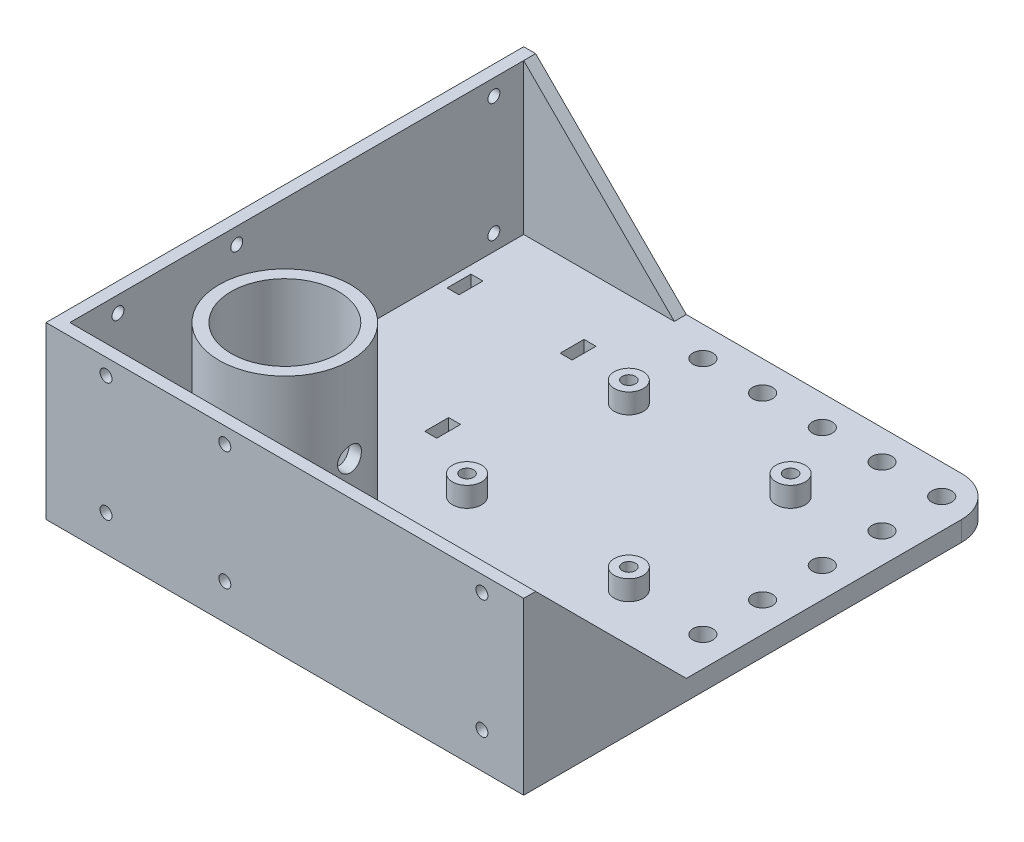
from build123d import *

# Parameters (mm, degrees)
SKETCH1_W           = 120
SKETCH1_H           = 120
BOSS_EXTRUDE1_DEPTH = 5
BOSS_EXTRUDE2_START = -5
BOSS_EXTRUDE2_DEPTH = 42.84
SKETCH6_R           = 1.5
CUT_EXTRUDE1_DEPTH  = 121
BOSS_EXTRUDE3_DEPTH = 3
SKETCH7_R           = 13.5
CUT_EXTRUDE2_DEPTH  = 6
SKETCH8_R           = 16.5
SKETCH8_R_2         = 13.5
BOSS_EXTRUDE5_DEPTH = 37.84
SKETCH9_R           = 3
CUT_EXTRUDE3_DEPTH  = 91
SKETCH10_R          = 2.5
SKETCH10_W          = 6
SKETCH10_H          = 3
CUT_EXTRUDE4_DEPTH  = 6.0000001
FILLET1_R           = 10
SKETCH11_R          = 1.65
CUT_EXTRUDE5_DEPTH  = 6.0000001
SKETCH12_R          = 3.65
SKETCH12_R_2        = 1.65
BOSS_EXTRUDE6_DEPTH = 5
CHAMFER1_SIZE       = 2.5


with BuildPart() as part:
    # Sketch1 → Boss-Extrude1 (new body)
    with BuildSketch(Plane(origin=(0, 0, 0), x_dir=(1, 0, 0), z_dir=(0, 1, 0))):
        with Locations((30, 30)):
            Rectangle(SKETCH1_W, SKETCH1_H)
    extrude(amount=-BOSS_EXTRUDE1_DEPTH)

    # Sketch2 → Boss-Extrude2 (add)
    with BuildSketch(Plane(origin=(0, 0, 0), x_dir=(1, 0, 0), z_dir=(0, 1, 0)).offset(BOSS_EXTRUDE2_START)):
        Polygon((-30, 90), (-27, 90), (-27, -27), (90, -27), (90, -30), (-30, -30), align=None)
    extrude(amount=BOSS_EXTRUDE2_DEPTH)

    # Sketch6 → Cut-Extrude1 (cut, through all)
    with BuildSketch(Plane.XY.offset(30)):
        with Locations((-14.919953083, 33.839953083)):
            Circle(SKETCH6_R)
        with Locations((14.919953083, 33.839953083)):
            Circle(SKETCH6_R)
        with Locations((14.919953083, 4.000046917)):
            Circle(SKETCH6_R)
        with Locations((-14.919953083, 4.000046917)):
            Circle(SKETCH6_R)
        with Locations((79.499953083, 33.839953083)):
            Circle(SKETCH6_R)
        with Locations((79.499953083, 4.000046917)):
            Circle(SKETCH6_R)
    cut_extrude1 = extrude(amount=-CUT_EXTRUDE1_DEPTH, mode=Mode.SUBTRACT)

    # Mirror1: Cut-Extrude1 across plane
    add(cut_extrude1.mirror(Plane(origin=(0, 0, 0), x_dir=(-0.707106781, 0, 0.707106781), z_dir=(-0.707106781, 0, -0.707106781))), mode=Mode.SUBTRACT)

    # Sketch3 → Boss-Extrude3 (add)
    with BuildSketch(Plane(origin=(90, 0, 0), x_dir=(0, 0, -1), z_dir=(1, 0, 0))):
        Polygon((-27, 37.84), (-27, 0), (10.84, 0), align=None)
    boss_extrude3 = extrude(amount=-BOSS_EXTRUDE3_DEPTH)

    # Sketch7 → Cut-Extrude2 (cut, through all)
    with BuildSketch(Plane(origin=(0, 0, 0), x_dir=(1, 0, 0), z_dir=(0, 1, 0))):
        Circle(SKETCH7_R)
    extrude(amount=-CUT_EXTRUDE2_DEPTH, mode=Mode.SUBTRACT)

    # Sketch8 → Boss-Extrude5 (add, through all)
    with BuildSketch(Plane(origin=(0, 0, 0), x_dir=(1, 0, 0), z_dir=(0, 1, 0))):
        Circle(SKETCH8_R)
        Circle(SKETCH8_R_2, mode=Mode.SUBTRACT)
    extrude(amount=BOSS_EXTRUDE5_DEPTH)

    # Sketch9 → Cut-Extrude3 (cut, through all)
    with BuildSketch(Plane(origin=(0, 0, 0), x_dir=(0, 0, -1), z_dir=(1, 0, 0))):
        with Locations((0, 16.42)):
            Circle(SKETCH9_R)
    cut_extrude3 = extrude(amount=CUT_EXTRUDE3_DEPTH, mode=Mode.SUBTRACT)

    # Sketch10 → Cut-Extrude4 (cut, through all)
    with BuildSketch(Plane(origin=(0, 0, 0), x_dir=(1, 0, 0), z_dir=(0, 1, 0))):
        with Locations((82.5, 82.5)):
            Circle(SKETCH10_R)
        with Locations((82.5, 67.5)):
            Circle(SKETCH10_R)
        with Locations((82.5, 52.5)):
            Circle(SKETCH10_R)
        with Locations((82.5, 37.5)):
            Circle(SKETCH10_R)
        with Locations((82.5, 22.5)):
            Circle(SKETCH10_R)
        with Locations((34.75, 4.9)):
            Rectangle(SKETCH10_W, SKETCH10_H)
        with Locations((68.75, 4.9)):
            Rectangle(SKETCH10_W, SKETCH10_H)
        with Locations((68.75, -23.5)):
            Rectangle(SKETCH10_W, SKETCH10_H)
        with Locations((34.75, -23.5)):
            Rectangle(SKETCH10_W, SKETCH10_H)
    cut_extrude4 = extrude(amount=-CUT_EXTRUDE4_DEPTH, mode=Mode.SUBTRACT)

    # Mirror2: Boss-Extrude3, Cut-Extrude3, Cut-Extrude4 across plane
    add(boss_extrude3.mirror(Plane(origin=(0, 0, 0), x_dir=(-0.707106781, 0, 0.707106781), z_dir=(-0.707106781, 0, -0.707106781))))
    add(cut_extrude3.mirror(Plane(origin=(0, 0, 0), x_dir=(-0.707106781, 0, 0.707106781), z_dir=(-0.707106781, 0, -0.707106781))), mode=Mode.SUBTRACT)
    add(cut_extrude4.mirror(Plane(origin=(0, 0, 0), x_dir=(-0.707106781, 0, 0.707106781), z_dir=(-0.707106781, 0, -0.707106781))), mode=Mode.SUBTRACT)

    # Fillet1
    fillet1_edges = [part.edges().sort_by_distance(p)[0] for p in [
        (90, -2.5, -90),
    ]]
    fillet(fillet1_edges, radius=FILLET1_R)

    # Sketch11 → Cut-Extrude5 (cut, through all)
    with BuildSketch(Plane(origin=(0, 0, 0), x_dir=(1, 0, 0), z_dir=(0, 1, 0))):
        with Locations((22.88, 63.52)):
            Circle(SKETCH11_R)
        with Locations((63.52, 63.52)):
            Circle(SKETCH11_R)
        with Locations((63.52, 22.88)):
            Circle(SKETCH11_R)
        with Locations((22.88, 22.88)):
            Circle(SKETCH11_R)
    extrude(amount=-CUT_EXTRUDE5_DEPTH, mode=Mode.SUBTRACT)

    # Sketch12 → Boss-Extrude6 (add)
    with BuildSketch(Plane(origin=(0, 0, 0), x_dir=(1, 0, 0), z_dir=(0, 1, 0))):
        with Locations((22.88, 63.52)):
            Circle(SKETCH12_R)
        with Locations((22.88, 63.52)):
            Circle(SKETCH12_R_2, mode=Mode.SUBTRACT)
        with Locations((63.52, 63.52)):
            Circle(SKETCH12_R)
        with Locations((63.52, 63.52)):
            Circle(SKETCH12_R_2, mode=Mode.SUBTRACT)
        with Locations((63.52, 22.88)):
            Circle(SKETCH12_R)
        with Locations((63.52, 22.88)):
            Circle(SKETCH12_R_2, mode=Mode.SUBTRACT)
        with Locations((22.88, 22.88)):
            Circle(SKETCH12_R)
        with Locations((22.88, 22.88)):
            Circle(SKETCH12_R_2, mode=Mode.SUBTRACT)
    extrude(amount=BOSS_EXTRUDE6_DEPTH)

    # Chamfer1
    chamfer1_edges = [part.edges().sort_by_distance(p)[0] for p in [
        (21.23, -5, -63.52),
        (61.87, -5, -22.88),
        (21.23, -5, -22.88),
        (61.87, -5, -63.52),
    ]]
    chamfer(chamfer1_edges, length=CHAMFER1_SIZE)


solid = part.part
